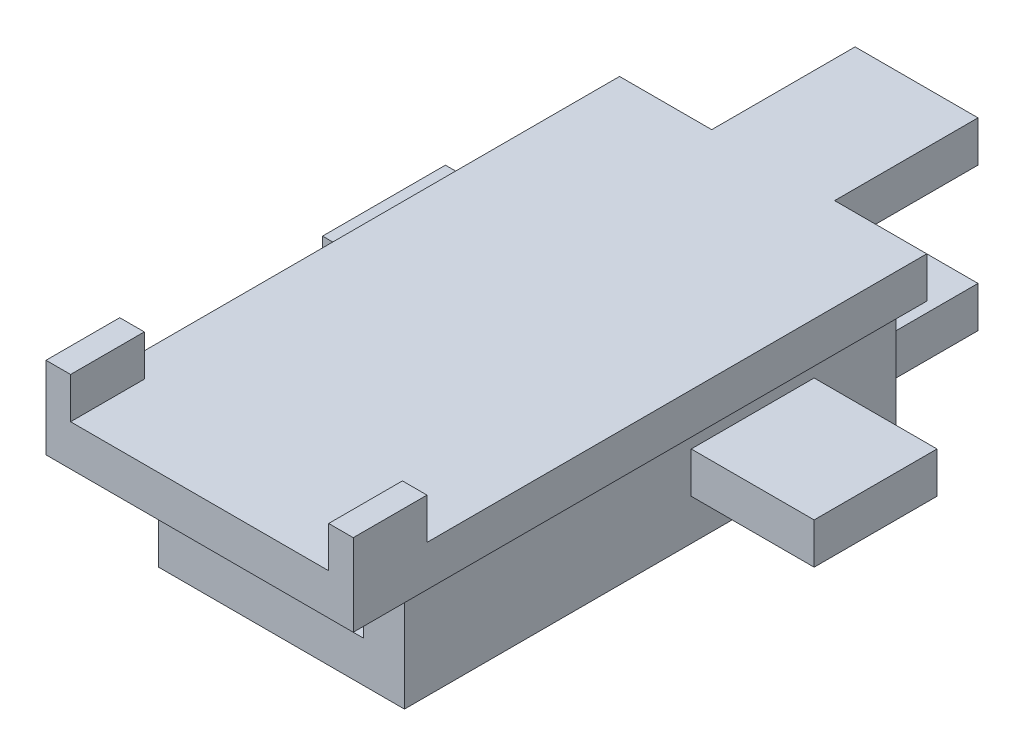
from build123d import *

# Parameters (mm, degrees)
SKETCH1_W            = 7.5
SKETCH1_H            = 10
BOSS_EXTRUDE1_DEPTH  = 1
SKETCH10_W           = 7.5
SKETCH10_H           = 1
BOSS_EXTRUDE5_DEPTH  = 2
SKETCH56_W           = 7.5
SKETCH56_H           = 1
BOSS_EXTRUDE17_DEPTH = 2
SKETCH57_W           = 3
SKETCH57_H           = 1
BOSS_EXTRUDE18_DEPTH = 5
SKETCH58_W           = 1.5
SKETCH58_H           = 1
BOSS_EXTRUDE19_DEPTH = 2
SKETCH59_W           = 1.5
SKETCH59_H           = 1
BOSS_EXTRUDE20_DEPTH = 2
SKETCH60_W           = 1
SKETCH60_H           = 1.5
BOSS_EXTRUDE23_DEPTH = 1.5
SKETCH61_W           = 1
SKETCH61_H           = 0.75
CUT_EXTRUDE1_DEPTH   = 0.5
SKETCH62_W           = 6
SKETCH62_H           = 12
BOSS_EXTRUDE25_DEPTH = 3
SKETCH64_W           = 4
SKETCH64_H           = 2
CUT_EXTRUDE2_DEPTH   = 12
SKETCH65_W           = 4
SKETCH65_H           = 1
BOSS_EXTRUDE26_DEPTH = 3
SKETCH66_R           = 1
CUT_EXTRUDE3_DEPTH   = 1
SKETCH69_W           = 7
SKETCH69_H           = 1.5
CUT_EXTRUDE8_DEPTH   = 10
SKETCH70_W           = 0.6
SKETCH70_H           = 1.8
BOSS_EXTRUDE27_DEPTH = 1
SKETCH68_W           = 3
SKETCH68_H           = 1
BOSS_EXTRUDE28_DEPTH = 3
SKETCH67_W           = 3
SKETCH67_H           = 1
BOSS_EXTRUDE29_DEPTH = 3


with BuildPart() as part:
    # Sketch1 → Boss-Extrude1 (new body)
    with BuildSketch(Plane(origin=(0, 0, 0), x_dir=(1, 0, 0), z_dir=(0, 1, 0))):
        Rectangle(SKETCH1_W, SKETCH1_H)
    extrude(amount=BOSS_EXTRUDE1_DEPTH)

    # Sketch10 → Boss-Extrude5 (add)
    with BuildSketch(Plane.XY.offset(5)):
        with Locations((0, 0.5)):
            Rectangle(SKETCH10_W, SKETCH10_H)
    extrude(amount=BOSS_EXTRUDE5_DEPTH)

    # Sketch56 → Boss-Extrude17 (add)
    with BuildSketch(Plane.XY.offset(7)):
        with Locations((0, 0.5)):
            Rectangle(SKETCH56_W, SKETCH56_H)
    extrude(amount=BOSS_EXTRUDE17_DEPTH)

    # Sketch57 → Boss-Extrude18 (add)
    with BuildSketch(Plane(origin=(0, 0, -5), x_dir=(-1, 0, 0), z_dir=(0, 0, -1))):
        with Locations((0, 0.5)):
            Rectangle(SKETCH57_W, SKETCH57_H)
    extrude(amount=BOSS_EXTRUDE18_DEPTH)

    # Sketch58 → Boss-Extrude19 (add)
    with BuildSketch(Plane(origin=(1.5, 0, 0), x_dir=(0, 0, -1), z_dir=(1, 0, 0))):
        with Locations((9.25, 0.5)):
            Rectangle(SKETCH58_W, SKETCH58_H)
    extrude(amount=BOSS_EXTRUDE19_DEPTH)

    # Sketch59 → Boss-Extrude20 (add)
    with BuildSketch(Plane.ZY.offset(1.5)):
        with Locations((-9.25, 0.5)):
            Rectangle(SKETCH59_W, SKETCH59_H)
    extrude(amount=BOSS_EXTRUDE20_DEPTH)

    # Sketch60 → Boss-Extrude23 (add)
    with BuildSketch(Plane(origin=(0, 1, 0), x_dir=(1, 0, 0), z_dir=(0, 1, 0))):
        with Locations((3, 9.25)):
            Rectangle(SKETCH60_W, SKETCH60_H)
        with Locations((-3, 9.25)):
            Rectangle(SKETCH60_W, SKETCH60_H)
    extrude(amount=BOSS_EXTRUDE23_DEPTH)

    # Sketch61 → Cut-Extrude1 (cut)
    with BuildSketch(Plane(origin=(0, 2.5, 0), x_dir=(1, 0, 0), z_dir=(0, 1, 0))):
        with Locations((-3, 9.245443114)):
            Rectangle(SKETCH61_W, SKETCH61_H)
        with Locations((3, 9.245443114)):
            Rectangle(SKETCH61_W, SKETCH61_H)
    extrude(amount=-CUT_EXTRUDE1_DEPTH, mode=Mode.SUBTRACT)

    # Sketch62 → Boss-Extrude25 (add)
    with BuildSketch(Plane(origin=(0, 0, 0), x_dir=(-1, 0, 0), z_dir=(0, -1, 0))):
        with Locations((0, -1)):
            Rectangle(SKETCH62_W, SKETCH62_H)
    extrude(amount=BOSS_EXTRUDE25_DEPTH)

    # Sketch64 → Cut-Extrude2 (cut)
    with BuildSketch(Plane.XY.offset(7)):
        with Locations((0, -1)):
            Rectangle(SKETCH64_W, SKETCH64_H)
    extrude(amount=-CUT_EXTRUDE2_DEPTH, mode=Mode.SUBTRACT)

    # Sketch65 → Boss-Extrude26 (add)
    with BuildSketch(Plane(origin=(0, 0, -5), x_dir=(-1, 0, 0), z_dir=(0, 0, -1))):
        with Locations((0, -2.5)):
            Rectangle(SKETCH65_W, SKETCH65_H)
    extrude(amount=BOSS_EXTRUDE26_DEPTH)

    # Sketch66 → Cut-Extrude3 (cut)
    with BuildSketch(Plane(origin=(0, -3, 0), x_dir=(-1, 0, 0), z_dir=(0, -1, 0))):
        with Locations((0, -5)):
            Circle(SKETCH66_R)
        with Locations((0, 5)):
            Circle(SKETCH66_R)
    extrude(amount=-CUT_EXTRUDE3_DEPTH, mode=Mode.SUBTRACT)

    # Sketch69 → Cut-Extrude8 (cut)
    with BuildSketch(Plane.XZ):
        with Locations((0, -9.25)):
            Rectangle(SKETCH69_W, SKETCH69_H)
    extrude(amount=-CUT_EXTRUDE8_DEPTH, mode=Mode.SUBTRACT)

    # Sketch70 → Boss-Extrude27 (add)
    with BuildSketch(Plane(origin=(0, 1, 0), x_dir=(1, 0, 0), z_dir=(0, 1, 0))):
        with Locations((-3.45, -8.1)):
            Rectangle(SKETCH70_W, SKETCH70_H)
        with Locations((3.45, -8.1)):
            Rectangle(SKETCH70_W, SKETCH70_H)
    extrude(amount=BOSS_EXTRUDE27_DEPTH)

    # Sketch68 → Boss-Extrude28 (add)
    with BuildSketch(Plane(origin=(3, 0, 0), x_dir=(0, 0, -1), z_dir=(1, 0, 0))):
        with Locations((1.5, -1.5)):
            Rectangle(SKETCH68_W, SKETCH68_H)
    extrude(amount=BOSS_EXTRUDE28_DEPTH)

    # Sketch67 → Boss-Extrude29 (add)
    with BuildSketch(Plane.ZY.offset(3)):
        with Locations((-1.5, -1.5)):
            Rectangle(SKETCH67_W, SKETCH67_H)
    extrude(amount=BOSS_EXTRUDE29_DEPTH)


solid = part.part
